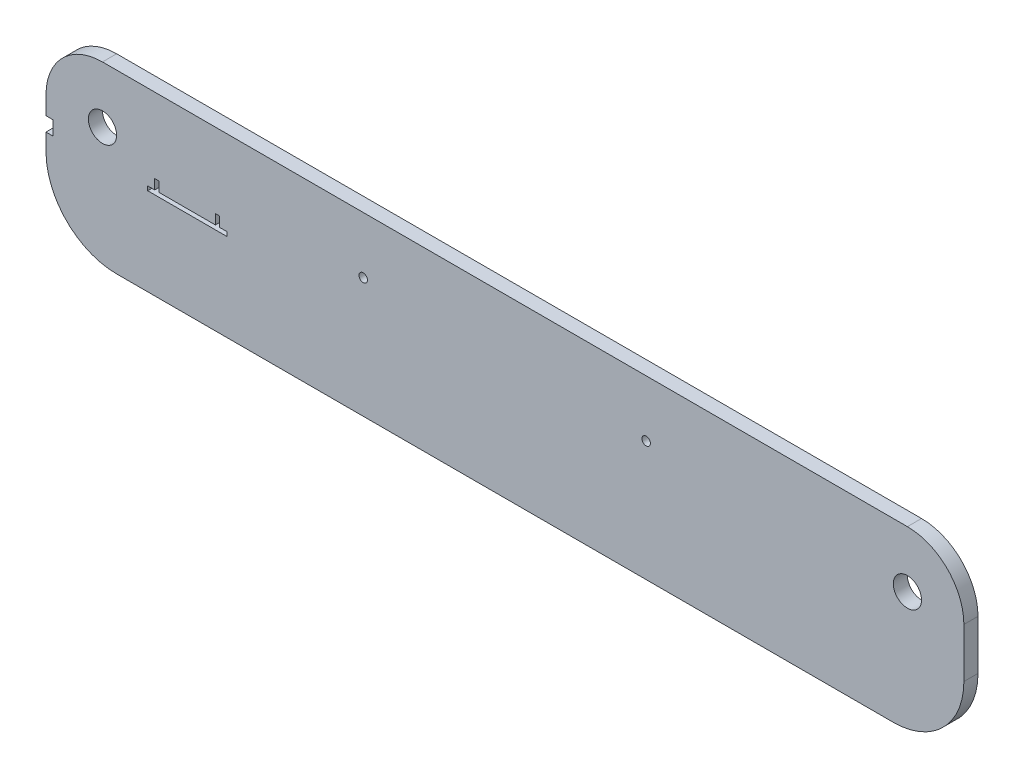
from build123d import *

# Parameters (mm, degrees)
SKETCH1_W           = 650
SKETCH1_H           = 125
BOSS_EXTRUDE1_DEPTH = 10
SKETCH2_R           = 10
CUT_EXTRUDE2_DEPTH  = 10
SKETCH3_R           = 10
CUT_EXTRUDE3_DEPTH  = 10
BOSS_EXTRUDE3_DEPTH = 20
SKETCH5_W           = 26
SKETCH5_H           = 3
CUT_EXTRUDE4_DEPTH  = 20
BOSS_EXTRUDE4_DEPTH = 20
SKETCH8_R           = 3
CUT_EXTRUDE5_DEPTH  = 20
FILLET1_R           = 50
FILLET2_R           = 40
FILLET3_R           = 50
FILLET4_R           = 40
SKETCH9_R           = 3
CUT_EXTRUDE6_DEPTH  = 10
SKETCH10_W          = 10
SKETCH10_H          = 10
CUT_EXTRUDE7_DEPTH  = 5
CUT_EXTRUDE8_DEPTH  = 30
SKETCH12_W          = 133
SKETCH12_H          = 20
CUT_EXTRUDE9_DEPTH  = 100
SKETCH13_W          = 20
SKETCH13_H          = 36
CUT_EXTRUDE10_DEPTH = 100


with BuildPart() as part:
    # Sketch1 → Boss-Extrude1 (new body)
    with BuildSketch(Plane.XY):
        with Locations((277.89592831, 25.809681948)):
            Rectangle(SKETCH1_W, SKETCH1_H)
    extrude(amount=BOSS_EXTRUDE1_DEPTH)

    # Sketch2 → Cut-Extrude2 (cut)
    with BuildSketch(Plane.XY.offset(10)):
        with Locations((-7.10407169, 48.309681948)):
            Circle(SKETCH2_R)
    extrude(amount=-CUT_EXTRUDE2_DEPTH, mode=Mode.SUBTRACT)

    # Sketch3 → Cut-Extrude3 (cut)
    with BuildSketch(Plane.XY.offset(10)):
        with Locations((562.89592831, 48.309681948)):
            Circle(SKETCH3_R)
    extrude(amount=-CUT_EXTRUDE3_DEPTH, mode=Mode.SUBTRACT)

    # Sketch4 → Boss-Extrude3 (add)
    with BuildSketch(Plane.XY.offset(10)):
        Polygon((32.89592831, 68.309681948), (72.89592831, 68.309681948), (72.89592831, 28.309681948), (32.89592831, 28.309681948), (32.89592831, 35.309681948), (29.89592831, 35.309681948), (29.89592831, 25.309681948), (75.89592831, 25.309681948), (75.89592831, 71.309681948), (29.89592831, 71.309681948), (29.89592831, 61.309681948), (32.89592831, 61.309681948), align=None)
    extrude(amount=BOSS_EXTRUDE3_DEPTH)

    # Sketch5 → Cut-Extrude4 (cut)
    with BuildSketch(Plane.XY.offset(30)):
        with Locations((52.89592831, 69.809681948)):
            Rectangle(SKETCH5_W, SKETCH5_H)
    extrude(amount=-CUT_EXTRUDE4_DEPTH, mode=Mode.SUBTRACT)

    # Sketch7 → Boss-Extrude4 (add)
    with BuildSketch(Plane.XY.offset(10)):
        Polygon((527.89592831, -36.690318052), (463.89592831, -36.690318052), (463.89592831, 25.309681948), (465.89592831, 25.309681948), (465.89592831, -34.690318052), (525.89592831, -34.690318052), (525.89592831, 25.309681948), (527.89592831, 25.309681948), align=None)
        Polygon((458.89592831, 25.309681948), (458.89592831, -36.690318052), (394.89592831, -36.690318052), (394.89592831, 25.309681948), (396.89592831, 25.309681948), (396.89592831, -34.690318052), (456.89592831, -34.690318052), (456.89592831, 25.309681948), align=None)
    extrude(amount=BOSS_EXTRUDE4_DEPTH)

    # Sketch8 → Cut-Extrude5 (cut)
    with BuildSketch(Plane.XY.offset(10)):
        with Locations((177.509070801, 48.309681948)):
            Circle(SKETCH8_R)
        with Locations((377.89592831, 48.309681948)):
            Circle(SKETCH8_R)
    extrude(amount=-CUT_EXTRUDE5_DEPTH, mode=Mode.SUBTRACT)

    # Fillet1
    fillet1_edges = [part.edges().sort_by_distance(p)[0] for p in [
        (602.89592831, -36.690318052, 5),
    ]]
    fillet(fillet1_edges, radius=FILLET1_R)

    # Fillet2
    fillet2_edges = [part.edges().sort_by_distance(p)[0] for p in [
        (602.89592831, 88.309681948, 5),
    ]]
    fillet(fillet2_edges, radius=FILLET2_R)

    # Fillet3
    fillet3_edges = [part.edges().sort_by_distance(p)[0] for p in [
        (-47.10407169, -36.690318052, 5),
    ]]
    fillet(fillet3_edges, radius=FILLET3_R)

    # Fillet4
    fillet4_edges = [part.edges().sort_by_distance(p)[0] for p in [
        (-47.10407169, 88.309681948, 5),
    ]]
    fillet(fillet4_edges, radius=FILLET4_R)

    # Sketch9 → Cut-Extrude6 (cut)
    with BuildSketch(Plane.ZY.offset(47.10407169)):
        with Locations((5, 30.309681948)):
            Circle(SKETCH9_R)
    extrude(amount=-CUT_EXTRUDE6_DEPTH, mode=Mode.SUBTRACT)

    # Sketch10 → Cut-Extrude7 (cut)
    with BuildSketch(Plane.ZY.offset(47.10407169)):
        with Locations((5, 30.309681948)):
            Rectangle(SKETCH10_W, SKETCH10_H)
    extrude(amount=-CUT_EXTRUDE7_DEPTH, mode=Mode.SUBTRACT)

    # Sketch11 → Cut-Extrude8 (cut)
    with BuildSketch(Plane.XY.offset(30)):
        Polygon((29.89592831, 35.309681948), (32.89592831, 35.309681948), (32.89592831, 28.309681948), (72.89592831, 28.309681948), (72.89592831, 35.309681948), (75.89592831, 35.309681948), (75.89592831, 28.309681948), (80.89592831, 28.309681948), (80.89592831, 25.309681948), (75.89592831, 25.309681948), (29.89592831, 25.309681948), (24.89592831, 25.309681948), (24.89592831, 28.309681948), (29.89592831, 28.309681948), align=None)
    extrude(amount=-CUT_EXTRUDE8_DEPTH, mode=Mode.SUBTRACT)

    # Sketch12 → Cut-Extrude9 (cut)
    with BuildSketch(Plane.XZ.offset(36.690318052)):
        with Locations((461.39592831, 20)):
            Rectangle(SKETCH12_W, SKETCH12_H)
    extrude(amount=-CUT_EXTRUDE9_DEPTH, mode=Mode.SUBTRACT)

    # Sketch13 → Cut-Extrude10 (cut)
    with BuildSketch(Plane(origin=(75.89592831, 0, 0), x_dir=(0, 0, -1), z_dir=(1, 0, 0))):
        with Locations((-20, 53.309681948)):
            Rectangle(SKETCH13_W, SKETCH13_H)
    extrude(amount=-CUT_EXTRUDE10_DEPTH, mode=Mode.SUBTRACT)


solid = part.part
